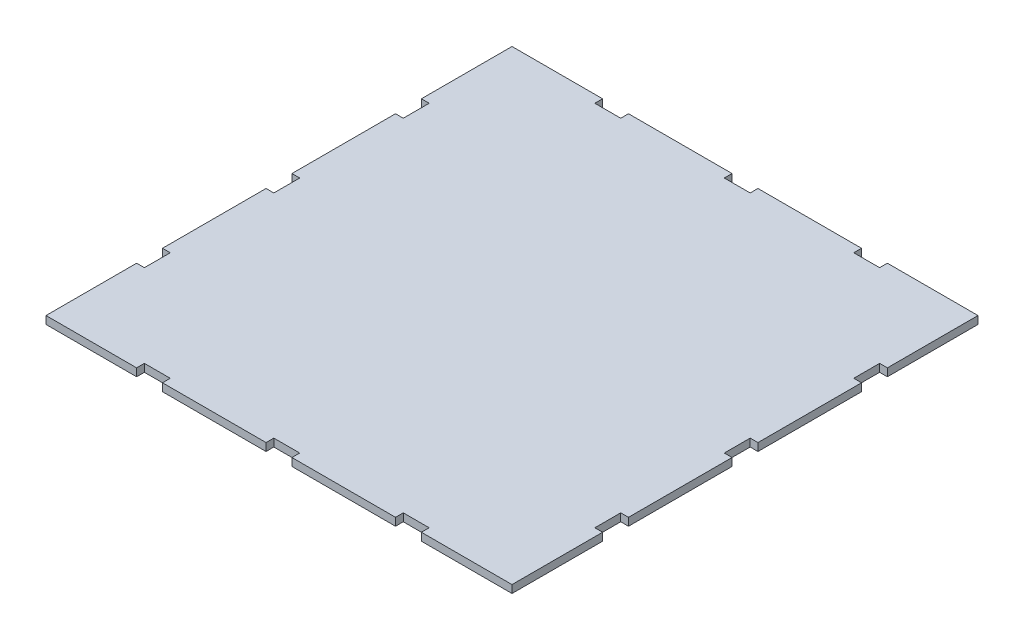
from build123d import *

# Parameters (mm, degrees)
SKETCH1_W           = 180
SKETCH1_H           = 180
BOSS_EXTRUDE1_DEPTH = 3
SKETCH2_W           = 5
SKETCH2_H           = 3
CUT_EXTRUDE1_DEPTH  = 3
SKETCH4_W           = 5
SKETCH4_H           = 3
CUT_EXTRUDE2_DEPTH  = 3
SKETCH5_W           = 3
SKETCH5_H           = 5
CUT_EXTRUDE3_DEPTH  = 3
SKETCH6_W           = 3
SKETCH6_H           = 5
CUT_EXTRUDE4_DEPTH  = 3
SKETCH7_W           = 10
SKETCH7_H           = 3
SKETCH7_W_2         = 3
SKETCH7_H_2         = 10
CUT_EXTRUDE5_DEPTH  = 10


with BuildPart() as part:
    # Sketch1 → Boss-Extrude1 (new body)
    with BuildSketch(Plane(origin=(0, 0, 0), x_dir=(1, 0, 0), z_dir=(0, 1, 0))):
        Rectangle(SKETCH1_W, SKETCH1_H)
    extrude(amount=BOSS_EXTRUDE1_DEPTH)

    # Sketch2 → Cut-Extrude1 (cut)
    with BuildSketch(Plane(origin=(0, 3, 0), x_dir=(1, 0, 0), z_dir=(0, 1, 0))):
        with Locations((-2.5, 88.5)):
            Rectangle(SKETCH2_W, SKETCH2_H)
        with Locations((2.5, 88.5)):
            Rectangle(SKETCH2_W, SKETCH2_H)
    extrude(amount=-CUT_EXTRUDE1_DEPTH, mode=Mode.SUBTRACT)

    # Sketch4 → Cut-Extrude2 (cut)
    with BuildSketch(Plane(origin=(0, 3, 0), x_dir=(1, 0, 0), z_dir=(0, 1, 0))):
        with Locations((-2.5, -88.5)):
            Rectangle(SKETCH4_W, SKETCH4_H)
        with Locations((2.5, -88.5)):
            Rectangle(SKETCH4_W, SKETCH4_H)
    extrude(amount=-CUT_EXTRUDE2_DEPTH, mode=Mode.SUBTRACT)

    # Sketch5 → Cut-Extrude3 (cut)
    with BuildSketch(Plane(origin=(0, 3, 0), x_dir=(1, 0, 0), z_dir=(0, 1, 0))):
        with Locations((-88.5, 2.5)):
            Rectangle(SKETCH5_W, SKETCH5_H)
        with Locations((-88.5, -2.5)):
            Rectangle(SKETCH5_W, SKETCH5_H)
    extrude(amount=-CUT_EXTRUDE3_DEPTH, mode=Mode.SUBTRACT)

    # Sketch6 → Cut-Extrude4 (cut)
    with BuildSketch(Plane(origin=(0, 3, 0), x_dir=(1, 0, 0), z_dir=(0, 1, 0))):
        with Locations((88.5, 2.5)):
            Rectangle(SKETCH6_W, SKETCH6_H)
        with Locations((88.5, -2.5)):
            Rectangle(SKETCH6_W, SKETCH6_H)
    extrude(amount=-CUT_EXTRUDE4_DEPTH, mode=Mode.SUBTRACT)

    # Sketch7 → Cut-Extrude5 (cut)
    with BuildSketch(Plane(origin=(0, 3, 0), x_dir=(1, 0, 0), z_dir=(0, 1, 0))):
        with Locations((-50, -88.5)):
            Rectangle(SKETCH7_W, SKETCH7_H)
        with Locations((50, -88.5)):
            Rectangle(SKETCH7_W, SKETCH7_H)
        with Locations((88.5, -50)):
            Rectangle(SKETCH7_W_2, SKETCH7_H_2)
        with Locations((50, 88.5)):
            Rectangle(SKETCH7_W, SKETCH7_H)
        with Locations((-88.5, -50)):
            Rectangle(SKETCH7_W_2, SKETCH7_H_2)
        with Locations((88.5, 50)):
            Rectangle(SKETCH7_W_2, SKETCH7_H_2)
        with Locations((-88.5, 50)):
            Rectangle(SKETCH7_W_2, SKETCH7_H_2)
        with Locations((-50, 88.5)):
            Rectangle(SKETCH7_W, SKETCH7_H)
    extrude(amount=-CUT_EXTRUDE5_DEPTH, mode=Mode.SUBTRACT)


solid = part.part
